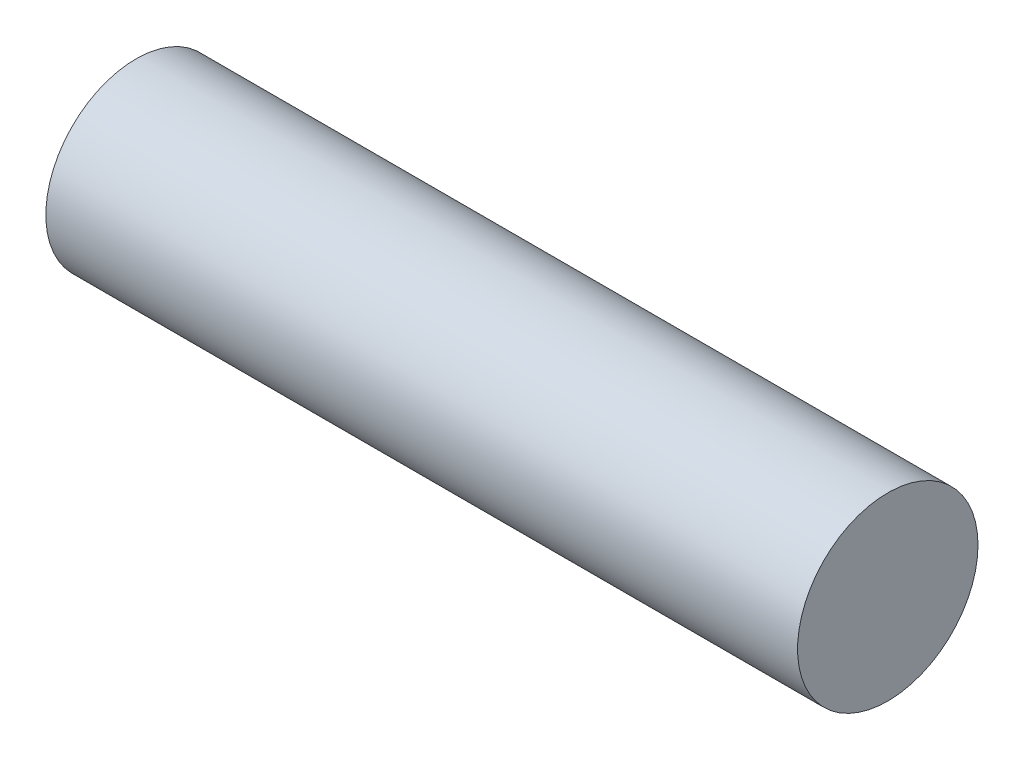
from build123d import *

# Parameters (mm, degrees)
SKETCH1_R           = 3
BOSS_EXTRUDE1_DEPTH = 25


with BuildPart() as part:
    # Sketch1 → Boss-Extrude1 (new body)
    with BuildSketch(Plane(origin=(0, 0, 0), x_dir=(0, 0, -1), z_dir=(1, 0, 0))):
        Circle(SKETCH1_R)
    extrude(amount=BOSS_EXTRUDE1_DEPTH)


solid = part.part
